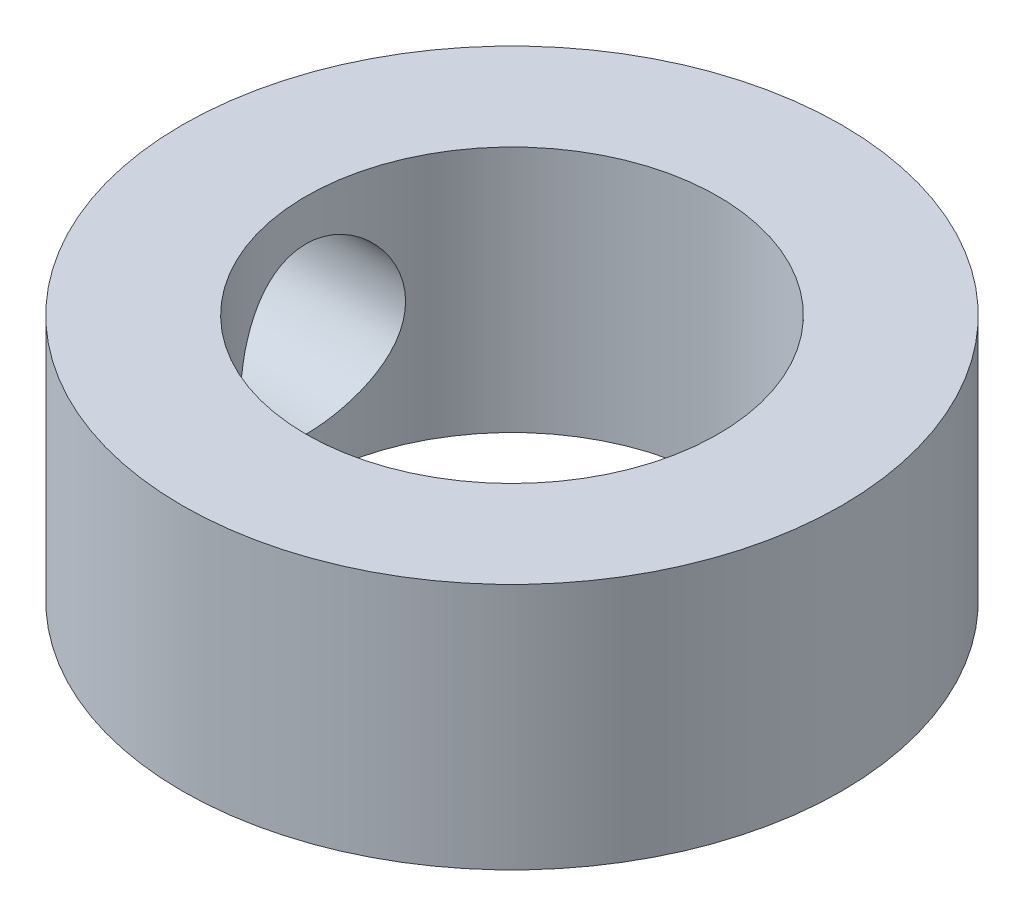
from build123d import *

# Parameters (mm, degrees)
SKETCH1_R           = 4
SKETCH1_R_2         = 2.5
BOSS_EXTRUDE1_DEPTH = 3
SKETCH2_R           = 1
CUT_EXTRUDE1_DEPTH  = 13


with BuildPart() as part:
    # Sketch1 → Boss-Extrude1 (new body)
    with BuildSketch(Plane(origin=(0, 0, 0), x_dir=(1, 0, 0), z_dir=(0, 1, 0))):
        Circle(SKETCH1_R)
        Circle(SKETCH1_R_2, mode=Mode.SUBTRACT)
    extrude(amount=BOSS_EXTRUDE1_DEPTH)

    # Sketch2 → Cut-Extrude1 (cut)
    with BuildSketch(Plane(origin=(0, 0, 0), x_dir=(0, 0, -1), z_dir=(1, 0, 0))):
        with Locations((0, 1.5)):
            Circle(SKETCH2_R)
    extrude(amount=-CUT_EXTRUDE1_DEPTH, mode=Mode.SUBTRACT)


solid = part.part
